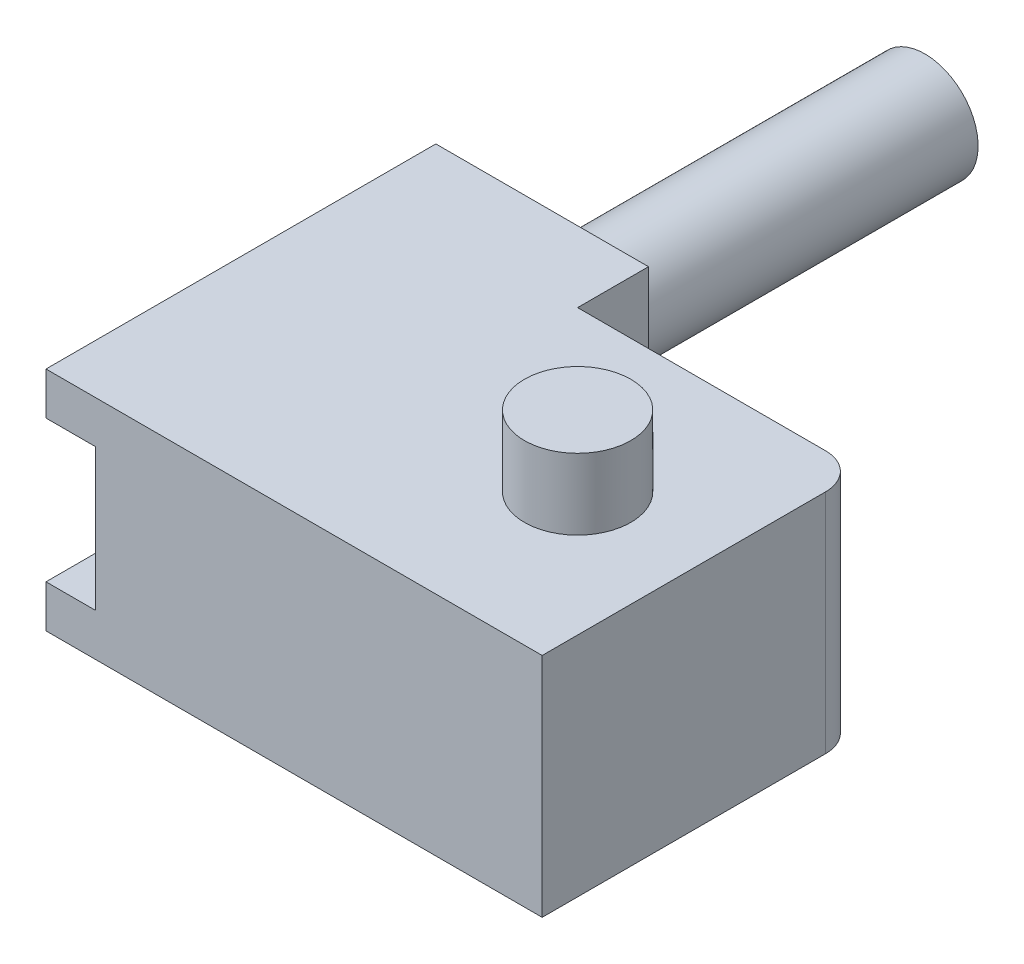
from build123d import *

# Parameters (mm, degrees)
CROQUIS2_W              = 70
CROQUIS2_H              = 40
SALIENTE_EXTRUIR1_DEPTH = 45
CROQUIS3_W              = 40.5
CROQUIS3_H              = 20
CORTAR_EXTRUIR1_DEPTH   = 39
CROQUIS4_W              = 7
CROQUIS4_H              = 20
CORTAR_EXTRUIR2_DEPTH   = 12
CROQUIS5_W              = 20
CROQUIS5_H              = 20
CORTAR_EXTRUIR4_DEPTH   = 7
CROQUIS6_R              = 7.5
SALIENTE_EXTRUIR3_DEPTH = 30
CROQUIS8_R              = 7.5
SALIENTE_EXTRUIR4_DEPTH = 30
CROQUIS9_W              = 30
CROQUIS9_H              = 40
SALIENTE_EXTRUIR5_DEPTH = 10
CROQUIS10_R             = 7.5
SALIENTE_EXTRUIR6_DEPTH = 54
REDONDEO1_R             = 5
CROQUIS11_W             = 42.231434226
CROQUIS11_H             = 4
CROQUIS11_W_2           = 30
CORTAR_EXTRUIR7_DEPTH   = 60
CROQUIS12_R             = 7.5
SALIENTE_EXTRUIR7_DEPTH = 100
CROQUIS13_W             = 75.549853641
CROQUIS13_H             = 40.129267471
CORTAR_EXTRUIR8_DEPTH   = 100


with BuildPart() as part:
    # Croquis2 → Saliente-Extruir1 (new body)
    with BuildSketch(Plane.XY):
        with Locations((35, 20)):
            Rectangle(CROQUIS2_W, CROQUIS2_H)
    extrude(amount=SALIENTE_EXTRUIR1_DEPTH)

    # Croquis3 → Cortar-Extruir1 (cut)
    with BuildSketch(Plane(origin=(0, 0, 0), x_dir=(-1, 0, 0), z_dir=(0, 0, -1))):
        with Locations((-27.25, 20)):
            Rectangle(CROQUIS3_W, CROQUIS3_H)
    extrude(amount=-CORTAR_EXTRUIR1_DEPTH, mode=Mode.SUBTRACT)

    # Croquis4 → Cortar-Extruir2 (cut)
    with BuildSketch(Plane(origin=(0, 0, 0), x_dir=(-1, 0, 0), z_dir=(0, 0, -1))):
        with Locations((-3.5, 20)):
            Rectangle(CROQUIS4_W, CROQUIS4_H)
        with Locations((-51, 20)):
            Rectangle(CROQUIS4_W, CROQUIS4_H)
    extrude(amount=-CORTAR_EXTRUIR2_DEPTH, mode=Mode.SUBTRACT)

    # Croquis5 → Cortar-Extruir4 (cut)
    with BuildSketch(Plane.ZY):
        with Locations((35, 20)):
            Rectangle(CROQUIS5_W, CROQUIS5_H)
    extrude(amount=-CORTAR_EXTRUIR4_DEPTH, mode=Mode.SUBTRACT)

    # Croquis6 → Saliente-Extruir3 (add)
    with BuildSketch(Plane(origin=(0, 40, 0), x_dir=(1, 0, 0), z_dir=(0, 1, 0))):
        with Locations((52.5, -22.5)):
            Circle(CROQUIS6_R)
    extrude(amount=SALIENTE_EXTRUIR3_DEPTH)

    # Croquis8 → Saliente-Extruir4 (add)
    with BuildSketch(Plane.XZ):
        with Locations((52.5, 22.5)):
            Circle(CROQUIS8_R)
    extrude(amount=SALIENTE_EXTRUIR4_DEPTH)

    # Croquis9 → Saliente-Extruir5 (add)
    with BuildSketch(Plane(origin=(0, 0, 0), x_dir=(-1, 0, 0), z_dir=(0, 0, -1))):
        with Locations((-15, 20)):
            Rectangle(CROQUIS9_W, CROQUIS9_H)
    extrude(amount=SALIENTE_EXTRUIR5_DEPTH)

    # Croquis10 → Saliente-Extruir6 (add)
    with BuildSketch(Plane(origin=(0, 0, -10), x_dir=(-1, 0, 0), z_dir=(0, 0, -1))):
        with Locations((-15, 20)):
            Circle(CROQUIS10_R)
    extrude(amount=SALIENTE_EXTRUIR6_DEPTH)

    # Redondeo1
    redondeo1_edges = [part.edges().sort_by_distance(p)[0] for p in [
        (70, 20, 0),
    ]]
    fillet(redondeo1_edges, radius=REDONDEO1_R)

    # Croquis11 → Cortar-Extruir7 (cut)
    with BuildSketch(Plane(origin=(0, 0, -10), x_dir=(-1, 0, 0), z_dir=(0, 0, -1))):
        with Locations((-51.115717113, 2)):
            Rectangle(CROQUIS11_W, CROQUIS11_H)
        with Locations((-51.115717113, 38)):
            Rectangle(CROQUIS11_W, CROQUIS11_H)
        with Locations((-15, 38)):
            Rectangle(CROQUIS11_W_2, CROQUIS11_H)
        with Locations((-15, 2)):
            Rectangle(CROQUIS11_W_2, CROQUIS11_H)
    extrude(amount=-CORTAR_EXTRUIR7_DEPTH, mode=Mode.SUBTRACT)

    # Croquis12 → Saliente-Extruir7 (add)
    with BuildSketch(Plane(origin=(0, 70, 0), x_dir=(1, 0, 0), z_dir=(0, 1, 0))):
        with Locations((52.5, -22.5)):
            Circle(CROQUIS12_R)
    extrude(amount=-SALIENTE_EXTRUIR7_DEPTH)

    # Croquis13 → Cortar-Extruir8 (cut)
    with BuildSketch(Plane(origin=(0, 0, -10), x_dir=(-1, 0, 0), z_dir=(0, 0, -1))):
        with Locations((-37.77492682, -26.064633736)):
            Rectangle(CROQUIS13_W, CROQUIS13_H)
        with Locations((-37.77492682, 66.064633735)):
            Rectangle(CROQUIS13_W, CROQUIS13_H)
    extrude(amount=-CORTAR_EXTRUIR8_DEPTH, mode=Mode.SUBTRACT)


solid = part.part
